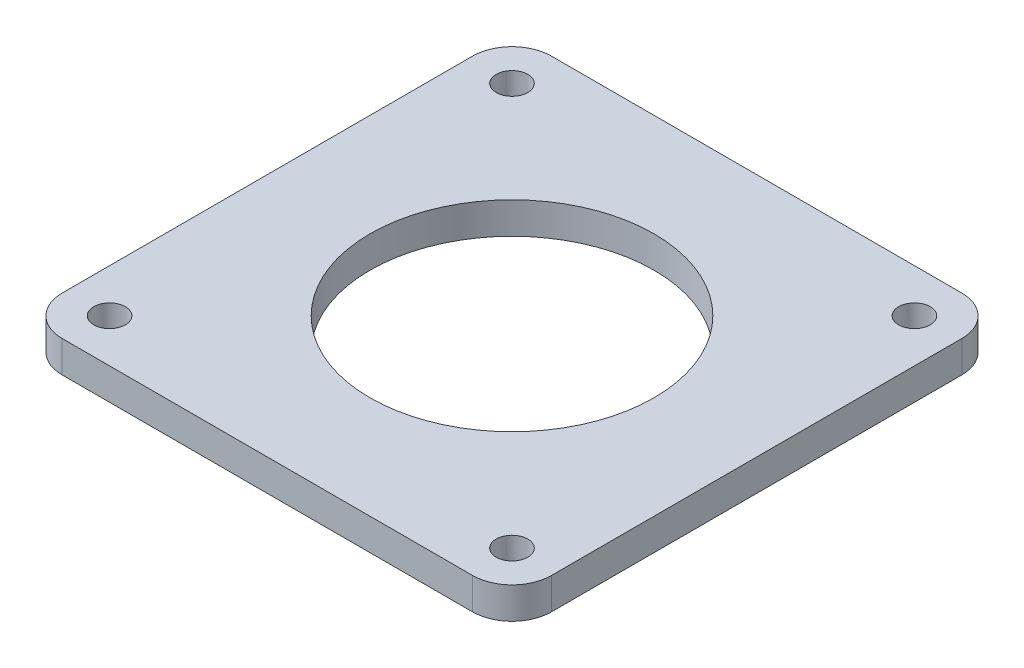
from build123d import *

# Parameters (mm, degrees)
SKETCH1_W           = 62
SKETCH1_H           = 62
SKETCH1_R           = 2
BOSS_EXTRUDE1_DEPTH = 4
SKETCH2_R           = 18
CUT_EXTRUDE1_DEPTH  = 10
FILLET1_R           = 5


with BuildPart() as part:
    # Sketch1 → Boss-Extrude1 (new body)
    with BuildSketch(Plane(origin=(0, 0, 0), x_dir=(1, 0, 0), z_dir=(0, 1, 0))):
        Rectangle(SKETCH1_W, SKETCH1_H)
        with Locations((25.5, 25.5)):
            Circle(SKETCH1_R, mode=Mode.SUBTRACT)
        with Locations((-25.5, 25.5)):
            Circle(SKETCH1_R, mode=Mode.SUBTRACT)
        with Locations((25.5, -25.5)):
            Circle(SKETCH1_R, mode=Mode.SUBTRACT)
        with Locations((-25.5, -25.5)):
            Circle(SKETCH1_R, mode=Mode.SUBTRACT)
    extrude(amount=BOSS_EXTRUDE1_DEPTH)

    # Sketch2 → Cut-Extrude1 (cut)
    with BuildSketch(Plane(origin=(0, 4, 0), x_dir=(1, 0, 0), z_dir=(0, 1, 0))):
        Circle(SKETCH2_R)
    extrude(amount=-CUT_EXTRUDE1_DEPTH, mode=Mode.SUBTRACT)

    # Fillet1
    fillet1_edges = [part.edges().sort_by_distance(p)[0] for p in [
        (-31, 2, 31),
        (-31, 2, -31),
        (31, 2, -31),
        (31, 2, 31),
    ]]
    fillet(fillet1_edges, radius=FILLET1_R)


solid = part.part
